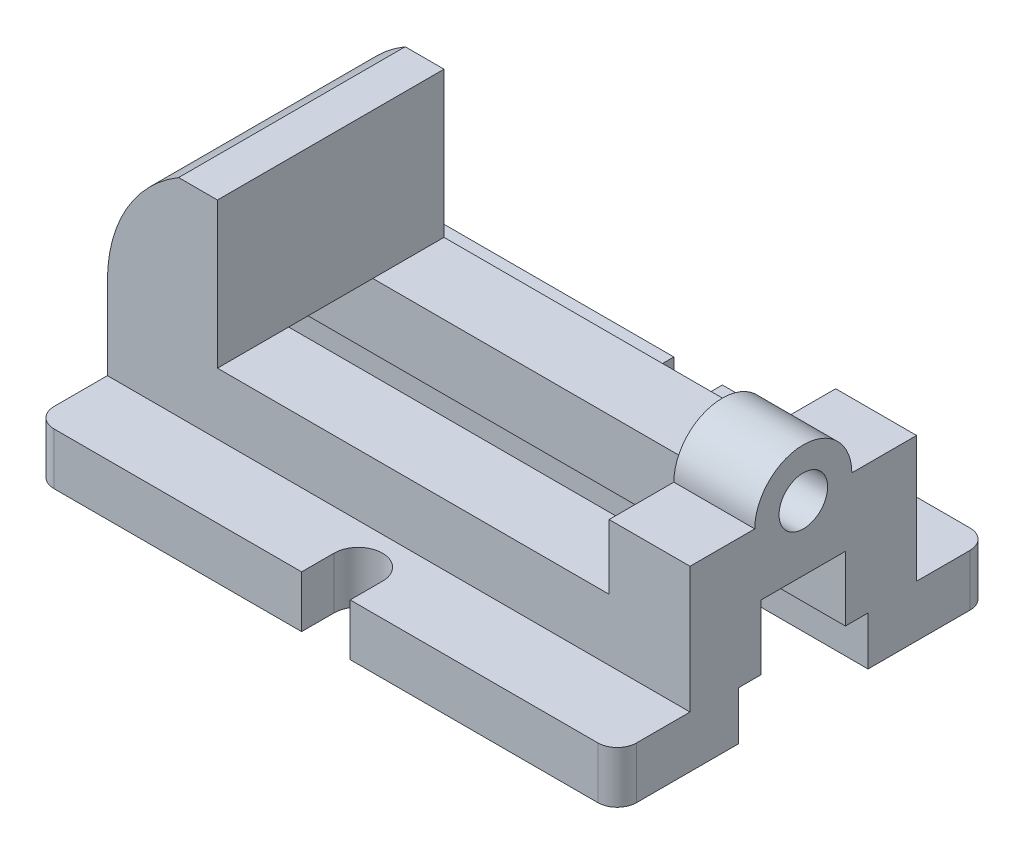
from build123d import *

# Parameters (mm, degrees)
BOSS_EXTRUDE1_DEPTH   = 90
BOSS_EXTRUDE1_2_DEPTH = 90
SKETCH2_R             = 7.5
BOSS_EXTRUDE2_DEPTH   = 25
BOSS_EXTRUDE3_DEPTH   = 70
FILLET1_R             = 6
CUT_EXTRUDE1_DEPTH    = 18.5


with BuildPart() as part:
    # Sketch1 → Boss-Extrude1 (new body, symmetric)
    with BuildSketch(Plane(origin=(0, 0, 0), x_dir=(0, 0, -1), z_dir=(1, 0, 0))):
        Polygon((13, 17.5), (35, 17.5), (35, -1.5), (57.5, -1.5), (57.5, -17.5), (20, -17.5), (20, -2.5), (13, -2.5), align=None)
    extrude(amount=BOSS_EXTRUDE1_DEPTH, both=True)



with BuildPart() as body_2:
    # Sketch1 → Boss-Extrude1 2 (new body, symmetric)
    with BuildSketch(Plane(origin=(0, 0, 0), x_dir=(0, 0, -1), z_dir=(1, 0, 0))):
        Polygon((-13, -2.5), (-13, 17.5), (-35, 17.5), (-35, -1.5), (-57.5, -1.5), (-57.5, -17.5), (-20, -17.5), (-20, -2.5), align=None)
    extrude(amount=BOSS_EXTRUDE1_2_DEPTH, both=True)


with BuildPart() as part_1:
    add(part.part)

    add(body_2.part)  # Boss-Extrude2 merges body 2
    # Sketch2 → Boss-Extrude2 (add)
    with BuildSketch(Plane(origin=(90, 0, 0), x_dir=(0, 0, -1), z_dir=(1, 0, 0))):
        with BuildLine():
            Line((35, 17.5), (-35, 17.5))
            Line((-35, 17.5), (-35, 37.5))
            Line((-35, 37.5), (-15, 37.5))
            ThreePointArc((-15, 37.5), (0, 52.5), (15, 37.5))
            Line((15, 37.5), (35, 37.5))
            Line((35, 37.5), (35, 17.5))
        make_face()
        with Locations((0, 37.5)):
            Circle(SKETCH2_R, mode=Mode.SUBTRACT)
    extrude(amount=-BOSS_EXTRUDE2_DEPTH)

    # Sketch3 → Boss-Extrude3 (add)
    with BuildSketch(Plane(origin=(0, 0, -35), x_dir=(-1, 0, 0), z_dir=(0, 0, -1))):
        with BuildLine():
            Line((90, 17.5), (56, 17.5))
            Line((56, 17.5), (56, 62.5))
            Line((56, 62.5), (68, 62.5))
            ThreePointArc((68, 62.5), (84.115214431, 46.07043625), (90, 23.821840788))
            Line((90, 23.821840788), (90, 17.5))
        make_face()
    extrude(amount=-BOSS_EXTRUDE3_DEPTH)

    # Fillet1
    fillet1_edges = [part_1.edges().sort_by_distance(p)[0] for p in [
        (90, -9.5, -57.5),
        (-90, -9.5, 57.5),
        (90, -9.5, 57.5),
        (-90, -9.5, -57.5),
    ]]
    fillet(fillet1_edges, radius=FILLET1_R)

    # Sketch4 → Cut-Extrude1 (cut, through all)
    with BuildSketch(Plane(origin=(0, 0, 0), x_dir=(1, 0, 0), z_dir=(0, 1, 0))):
        with BuildLine():
            Line((7.5, 67.5), (7.5, 47.5))
            ThreePointArc((7.5, 47.5), (0, 40), (-7.5, 47.5))
            Line((-7.5, 47.5), (-7.5, 67.5))
            ThreePointArc((-7.5, 67.5), (0, 75), (7.5, 67.5))
        make_face()
        with BuildLine():
            Line((-7.5, -67.5), (-7.5, -47.5))
            ThreePointArc((-7.5, -47.5), (0, -40), (7.5, -47.5))
            Line((7.5, -47.5), (7.5, -67.5))
            ThreePointArc((7.5, -67.5), (0, -75), (-7.5, -67.5))
        make_face()
    extrude(amount=-CUT_EXTRUDE1_DEPTH, mode=Mode.SUBTRACT)


solid = part_1.part
